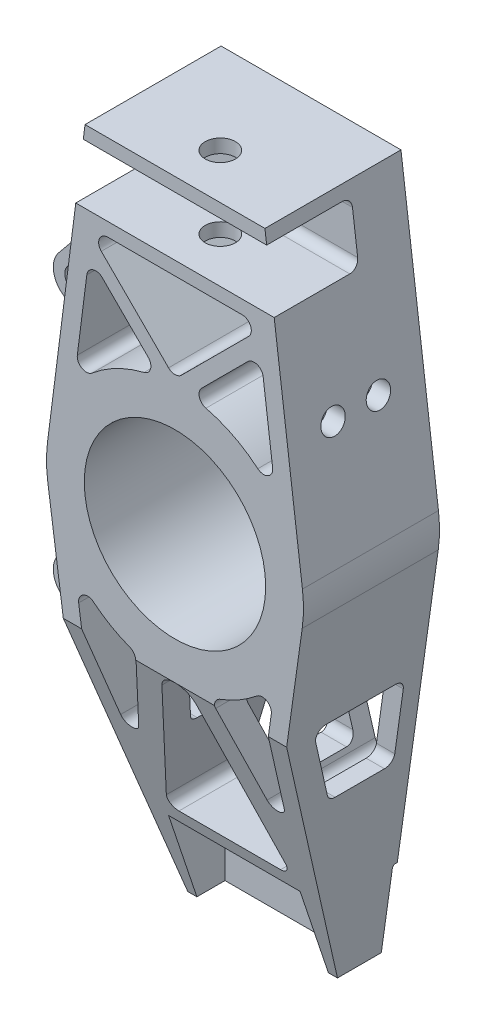
from build123d import *

# Parameters (mm, degrees)
SKETCH1_R                      = 30
SKETCH1_R_2                    = 3
BOSS_EXTRUDE1_DEPTH            = 22.5
CUT_EXTRUDE1_START             = 6.7
SKETCH2_W                      = 43.5
SKETCH2_H                      = 28
CUT_EXTRUDE1_DEPTH             = 45
CUT_EXTRUDE3_DEPTH             = 43.5
CUT_EXTRUDE3_DEPTH_BACK        = 43.5
SKETCH7_R                      = 5
CUT_EXTRUDE4_DEPTH             = 28.5
CUT_EXTRUDE5_REACH             = 44.5
CUT_EXTRUDE5_DIRECTION_2_DEPTH = 43.5
CUT_EXTRUDE6_START             = 30.728059
SKETCH10_R                     = 4
CUT_EXTRUDE6_DEPTH             = 7.070855
SKETCH12_R                     = 4
BOSS_EXTRUDE2_DEPTH            = 10


with BuildPart() as part:
    # Sketch1 → Boss-Extrude1 (new body, symmetric)
    with BuildSketch(Plane.XY):
        with BuildLine():
            Line((-29.75, 102.5), (-42.157330806, 5.38604301))
            ThreePointArc((-42.157330806, 5.38604301), (-42.499156405, -0.267777651), (-42.086113863, -5.916842057))
            Line((-42.086113863, -5.916842057), (-37.836662433, -36.142914512))
            Line((-37.836662433, -36.142914512), (-30.179572712, -90.607297158))
            Line((-30.179572712, -90.607297158), (-24.75, -129.227495762))
            Line((-24.75, -129.227495762), (24.75, -129.227495762))
            Line((24.75, -129.227495762), (42.086113863, -5.916842057))
            ThreePointArc((42.086113863, -5.916842057), (42.499156405, -0.267777651), (42.157330806, 5.38604301))
            Line((42.157330806, 5.38604301), (29.75, 102.5))
            Line((29.75, 102.5), (-29.75, 102.5))
        make_face()
        Circle(SKETCH1_R, mode=Mode.SUBTRACT)
        with Locations((-12, -115.227495762)):
            Circle(SKETCH1_R_2, mode=Mode.SUBTRACT)
        with Locations((12, -115.227495762)):
            Circle(SKETCH1_R_2, mode=Mode.SUBTRACT)
        with BuildLine():
            Line((-31.858021287, -35.571287293), (-27.062097865, -69.684379585))
            ThreePointArc((-27.062097865, -69.684379585), (-24.322273449, -72.257816506), (-21.219861823, -70.135492892))
            Line((-21.219861823, -70.135492892), (-13.147714601, -43.455581929))
            ThreePointArc((-13.147714601, -43.455581929), (-13.329157036, -41.258708643), (-14.96295738, -39.778887698))
            ThreePointArc((-14.96295738, -39.778887698), (-21.258144353, -36.801376315), (-26.982583804, -32.835806237))
            ThreePointArc((-26.982583804, -32.835806237), (-30.355185437, -32.537308543), (-31.858021287, -35.571287293))
        make_face(mode=Mode.SUBTRACT)
        with BuildLine():
            Line((31.858021287, -35.571287293), (27.062097865, -69.684379585))
            ThreePointArc((27.062097865, -69.684379585), (24.322273449, -72.257816506), (21.219861823, -70.135492892))
            Line((21.219861823, -70.135492892), (13.147714601, -43.455581929))
            ThreePointArc((13.147714601, -43.455581929), (13.329157036, -41.258708643), (14.96295738, -39.778887698))
            ThreePointArc((14.96295738, -39.778887698), (21.258144353, -36.801376315), (26.982583804, -32.835806237))
            ThreePointArc((26.982583804, -32.835806237), (30.355185437, -32.537308543), (31.858021287, -35.571287293))
        make_face(mode=Mode.SUBTRACT)
        with BuildLine():
            Line((-29.161510987, 59.761597506), (-32.303727483, 35.167018507))
            ThreePointArc((-32.303727483, 35.167018507), (-30.762779632, 32.152217955), (-27.394207157, 32.493190275))
            ThreePointArc((-27.394207157, 32.493190275), (-19.319896855, 37.85487532), (-10.240768442, 41.247747353))
            ThreePointArc((-10.240768442, 41.247747353), (-8.073152856, 43.356204158), (-8.842325871, 46.280673392))
            Line((-8.842325871, 46.280673392), (-24.064379057, 61.502726578))
            ThreePointArc((-24.064379057, 61.502726578), (-27.155452685, 62.220345925), (-29.161510987, 59.761597506))
        make_face(mode=Mode.SUBTRACT)
        with BuildLine():
            Line((29.161510987, 59.761597506), (32.303727483, 35.167018507))
            ThreePointArc((32.303727483, 35.167018507), (30.762779632, 32.152217955), (27.394207157, 32.493190275))
            ThreePointArc((27.394207157, 32.493190275), (19.319896855, 37.85487532), (10.240768442, 41.247747353))
            ThreePointArc((10.240768442, 41.247747353), (8.073152856, 43.356204158), (8.842325871, 46.280673392))
            Line((8.842325871, 46.280673392), (24.064379057, 61.502726578))
            ThreePointArc((24.064379057, 61.502726578), (27.155452685, 62.220345925), (29.161510987, 59.761597506))
        make_face(mode=Mode.SUBTRACT)
        with BuildLine():
            Line((-22.24794398, 74), (22.24794398, 74))
            ThreePointArc((22.24794398, 74), (25.019582578, 72.148050297), (24.369264324, 68.878679656))
            Line((24.369264324, 68.878679656), (2.121320344, 46.630735676))
            ThreePointArc((2.121320344, 46.630735676), (0, 45.75205602), (-2.121320344, 46.630735676))
            Line((-2.121320344, 46.630735676), (-24.369264324, 68.878679656))
            ThreePointArc((-24.369264324, 68.878679656), (-25.019582578, 72.148050297), (-22.24794398, 74))
        make_face(mode=Mode.SUBTRACT)
        with BuildLine():
            Line((-16.818119733, -96.727495762), (16.818119733, -96.727495762))
            ThreePointArc((16.818119733, -96.727495762), (19.227094436, -95.515466925), (19.689571267, -92.858723015))
            Line((19.689571267, -92.858723015), (5.742903069, -46.762454507))
            ThreePointArc((5.742903069, -46.762454507), (0, -42.5), (-5.742903069, -46.762454507))
            Line((-5.742903069, -46.762454507), (-19.689571267, -92.858723015))
            ThreePointArc((-19.689571267, -92.858723015), (-19.227094436, -95.515466925), (-16.818119733, -96.727495762))
        make_face(mode=Mode.SUBTRACT)
    extrude(amount=BOSS_EXTRUDE1_DEPTH, both=True)

    # Sketch2 → Cut-Extrude1 (cut)
    with BuildSketch(Plane.XY.offset(22.5).offset(CUT_EXTRUDE1_START)):
        with Locations((0, -115.227495762)):
            Rectangle(SKETCH2_W, SKETCH2_H)
    extrude(amount=-CUT_EXTRUDE1_DEPTH, mode=Mode.SUBTRACT)

    # Sketch6 → Cut-Extrude3 (cut, two sides)
    with BuildSketch(Plane(origin=(0, 0, 0), x_dir=(0, 0, -1), z_dir=(1, 0, 0))) as cut_extrude3_sk:
        with BuildLine():
            Line((22.5, -102.227495762), (22, -102.227495762))
            ThreePointArc((22, -102.227495762), (21.292893219, -102.52038898), (21, -103.227495762))
            Line((21, -103.227495762), (21, -129.227495762))
            Line((21, -129.227495762), (22.5, -129.227495762))
            Line((22.5, -129.227495762), (22.5, -102.227495762))
        make_face()
        Polygon((6.5, -129.227495762), (-22.5, -42.52418893), (-22.5, -129.227495762), align=None)
        with BuildLine():
            Line((-22.5, 98), (2.5, 98))
            ThreePointArc((2.5, 98), (4.621320344, 97.121320344), (5.5, 95))
            Line((5.5, 95), (5.5, 81.5))
            ThreePointArc((5.5, 81.5), (4.621320344, 79.378679656), (2.5, 78.5))
            Line((2.5, 78.5), (-22.5, 78.5))
            Line((-22.5, 78.5), (-22.5, 98))
        make_face()
    extrude(amount=CUT_EXTRUDE3_DEPTH, mode=Mode.SUBTRACT)
    extrude(cut_extrude3_sk.sketch, amount=-CUT_EXTRUDE3_DEPTH_BACK, mode=Mode.SUBTRACT)

    # Sketch7 → Cut-Extrude4 (cut)
    with BuildSketch(Plane(origin=(0, 102.5, 0), x_dir=(1, 0, 0), z_dir=(0, 1, 0))):
        with Locations((0, -7.5)):
            Circle(SKETCH7_R)
    extrude(amount=-CUT_EXTRUDE4_DEPTH, mode=Mode.SUBTRACT)

    # Cut-Extrude5: up to this face of the body (flat: up to its plane)
    cut_extrude5_end = Plane(part.part.faces().sort_by_distance((-29.558383843, -51.928459306, -1.701595807))[0])
    # Sketch8 → Cut-Extrude5 (cut, up to the picked face)
    with BuildSketch(Plane(origin=(0, 0, 0), x_dir=(0, 0, -1), z_dir=(1, 0, 0)), mode=Mode.PRIVATE) as cut_extrude5_sk1:
        with BuildLine():
            Line((-9.5, -42.52418893), (13.5, -42.52418893))
            ThreePointArc((13.5, -42.52418893), (15.621320344, -43.402868586), (16.5, -45.52418893))
            Line((16.5, -45.52418893), (16.5, -65.52418893))
            ThreePointArc((16.5, -65.52418893), (15.621320344, -67.645509274), (13.5, -68.52418893))
            Line((13.5, -68.52418893), (-2.810520427, -68.52418893))
            ThreePointArc((-2.810520427, -68.52418893), (-4.563402269, -67.958815235), (-5.655595256, -66.475792428))
            Line((-5.655595256, -66.475792428), (-12.345074829, -46.475792428))
            ThreePointArc((-12.345074829, -46.475792428), (-11.934626305, -43.771307088), (-9.5, -42.52418893))
        make_face()
    cut_extrude5_tool1 = split(extrude(cut_extrude5_sk1.sketch, amount=-CUT_EXTRUDE5_REACH, mode=Mode.PRIVATE), bisect_by=cut_extrude5_end, keep=Keep.BOTH, mode=Mode.PRIVATE)
    add(cut_extrude5_tool1.solids().sort_by_distance((0, -54.840923, -3.502309))[0], mode=Mode.SUBTRACT)

    # Sketch8 → Cut-Extrude5 direction 2 (cut)
    with BuildSketch(Plane(origin=(0, 0, 0), x_dir=(0, 0, -1), z_dir=(1, 0, 0))):
        with BuildLine():
            Line((-9.5, -42.52418893), (13.5, -42.52418893))
            ThreePointArc((13.5, -42.52418893), (15.621320344, -43.402868586), (16.5, -45.52418893))
            Line((16.5, -45.52418893), (16.5, -65.52418893))
            ThreePointArc((16.5, -65.52418893), (15.621320344, -67.645509274), (13.5, -68.52418893))
            Line((13.5, -68.52418893), (-2.810520427, -68.52418893))
            ThreePointArc((-2.810520427, -68.52418893), (-4.563402269, -67.958815235), (-5.655595256, -66.475792428))
            Line((-5.655595256, -66.475792428), (-12.345074829, -46.475792428))
            ThreePointArc((-12.345074829, -46.475792428), (-11.934626305, -43.771307088), (-9.5, -42.52418893))
        make_face()
    extrude(amount=CUT_EXTRUDE5_DIRECTION_2_DEPTH, mode=Mode.SUBTRACT)

    # Sketch10 → Cut-Extrude6 (cut)
    with BuildSketch(Plane(origin=(0, 0, 0), x_dir=(0, 0, -1), z_dir=(1, 0, 0)).offset(CUT_EXTRUDE6_START)):
        with Locations((-7.5, 43.5)):
            Circle(SKETCH10_R)
        with Locations((7.5, 43.5)):
            Circle(SKETCH10_R)
    extrude(amount=CUT_EXTRUDE6_DEPTH, mode=Mode.SUBTRACT)

    # Sketch12 → Boss-Extrude2 (add)
    with BuildSketch(Plane.XY.offset(-4.1)):
        with BuildLine():
            Line((-63.920817999, -62.786011), (-30.318792525, -89.617035655))
            Line((-30.318792525, -89.617035655), (-32.358565194, -75.108264932))
            ThreePointArc((-32.358565194, -75.108264932), (-34.348162194, -77.062609365), (-37.086664818, -76.534819861))
            Line((-37.086664818, -76.534819861), (-51.789633557, -64.794583636))
            ThreePointArc((-51.789633557, -64.794583636), (-52.875842208, -62.949660087), (-52.455505303, -60.850396163))
            ThreePointArc((-52.455505303, -60.850396163), (-51.262914316, -57.067826683), (-52.084645666, -53.187767054))
            ThreePointArc((-52.084645666, -53.187767054), (-52.300290454, -51.05772258), (-51.040992939, -49.326317975))
            Line((-51.040992939, -49.326317975), (-41.1344423, -42.876832559))
            ThreePointArc((-41.1344423, -42.876832559), (-38.552217057, -42.543846422), (-36.682090701, -44.355308369))
            Line((-36.682090701, -44.355308369), (-38.168005588, -33.786092136))
            Line((-38.168005588, -33.786092136), (-63.309447087, -50.153985078))
            ThreePointArc((-63.309447087, -50.153985078), (-66.844675528, -56.313693053), (-63.920817999, -62.786011))
        make_face()
        with Locations((-59.053794922, -56.690759868)):
            Circle(SKETCH12_R, mode=Mode.SUBTRACT)
        with BuildLine():
            Line((-36.218004492, 51.874001562), (-33.455055427, 73.5))
            Line((-33.455055427, 73.5), (-65.093635199, 34.783075148))
            ThreePointArc((-65.093635199, 34.783075148), (-66.728495932, 28.454989682), (-62.974738262, 23.104593564))
            Line((-62.974738262, 23.104593564), (-41.489764294, 10.611181809))
            Line((-41.489764294, 10.611181809), (-40.091055493, 21.559076113))
            ThreePointArc((-40.091055493, 21.559076113), (-41.739026607, 19.249129901), (-44.574922211, 19.345858485))
            Line((-44.574922211, 19.345858485), (-50.680166251, 22.896029304))
            ThreePointArc((-50.680166251, 22.896029304), (-52.025088315, 24.561795427), (-51.917023287, 26.699998898))
            ThreePointArc((-51.917023287, 26.699998898), (-51.379093911, 31.239923724), (-53.477644512, 35.301496179))
            ThreePointArc((-53.477644512, 35.301496179), (-54.329987985, 37.265446978), (-53.655986769, 39.297518457))
            Line((-53.655986769, 39.297518457), (-41.516831569, 54.152507619))
            ThreePointArc((-41.516831569, 54.152507619), (-38.008728255, 55.01019843), (-36.218004492, 51.874001562))
        make_face()
        with Locations((-59.053794922, 29.847456703)):
            Circle(SKETCH12_R, mode=Mode.SUBTRACT)
    extrude(amount=-BOSS_EXTRUDE2_DEPTH)


solid = part.part
